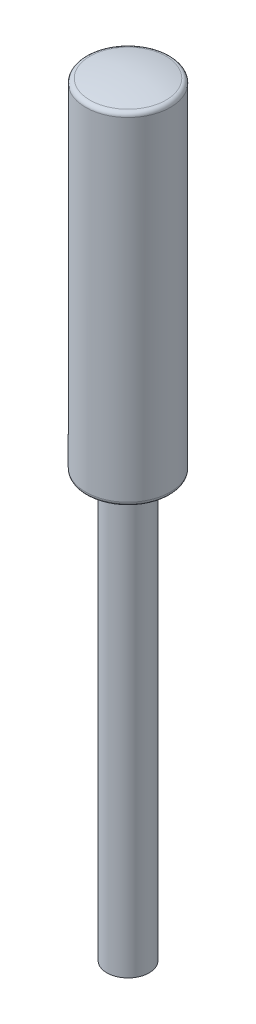
from build123d import *

# Parameters (mm, degrees)
FILLET1_R         = 0.5
DOME1_FACE_RADIUS = 4.5
DOME1_HEIGHT      = 0.5


with BuildPart() as part:
    # Sketch1 → Revolve1 (revolve)
    with BuildSketch(Plane.XY):
        Polygon((0, 0), (5, 0), (5, -40.4), (2.5, -40.4), (2.5, -90.4), (0, -90.4), align=None)
    revolve(axis=Axis((0, -90.4, 0), (0, 1, 0)))

    # Fillet1
    fillet1_edges = [part.edges().sort_by_distance(p)[0] for p in [
        (-5, -40.4, 0),
        (-5, 0, 0),
    ]]
    fillet(fillet1_edges, radius=FILLET1_R)

    # Dome1: a dome of height H over a round flat face of radius A is a cap of a sphere of radius (A * A + H * H) / (2 * H)
    dome1_r = (DOME1_FACE_RADIUS * DOME1_FACE_RADIUS + DOME1_HEIGHT * DOME1_HEIGHT) / (2 * DOME1_HEIGHT)
    dome1_base = Plane((0, 0, 0), z_dir=(0, 1, 0))
    with Locations(dome1_base.offset(DOME1_HEIGHT - dome1_r)):
        dome1_ball = Sphere(dome1_r, mode=Mode.PRIVATE)
    add(split(dome1_ball, bisect_by=dome1_base, keep=Keep.TOP, mode=Mode.PRIVATE))


solid = part.part
